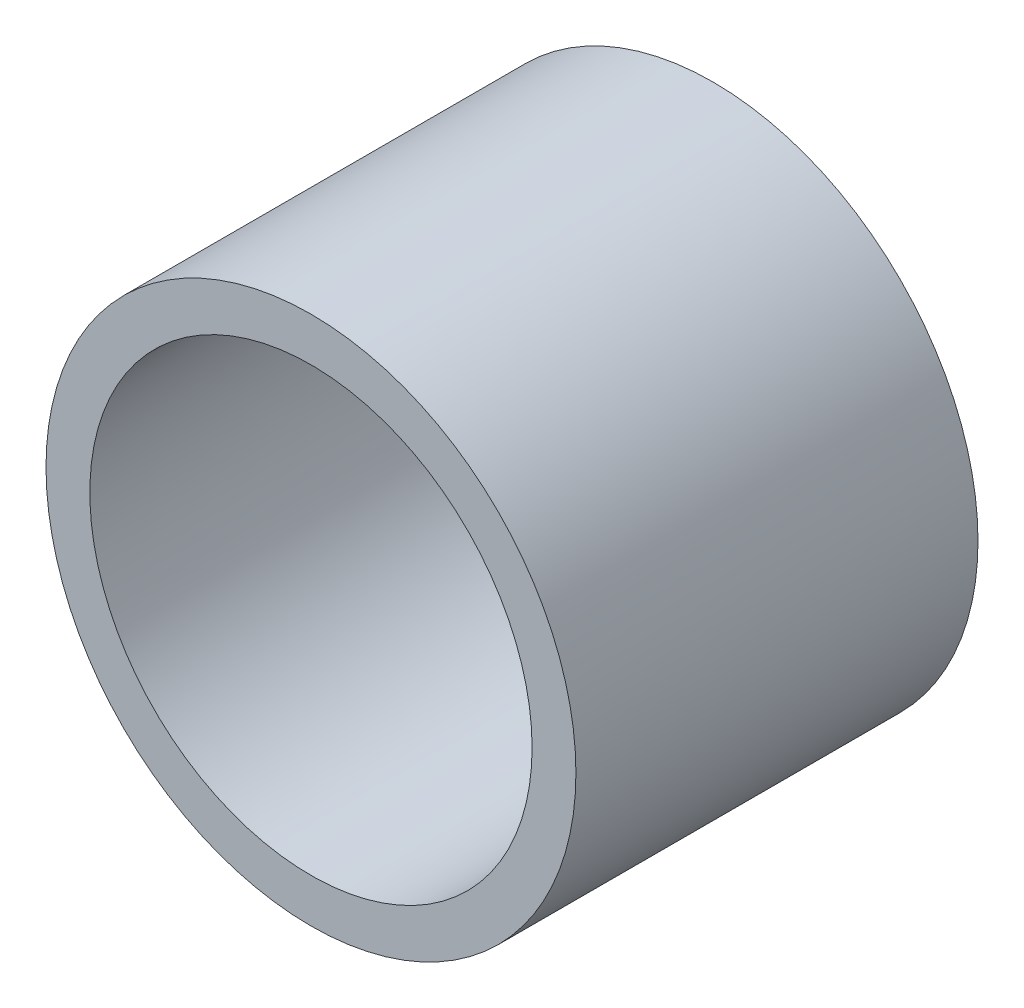
from build123d import *

# Parameters (mm, degrees)
SKETCH1_R           = 32.95
SKETCH1_R_2         = 27.5
BOSS_EXTRUDE1_DEPTH = 50


with BuildPart() as part:
    # Sketch1 → Boss-Extrude1 (new body)
    with BuildSketch(Plane.XY):
        Circle(SKETCH1_R)
        Circle(SKETCH1_R_2, mode=Mode.SUBTRACT)
    extrude(amount=BOSS_EXTRUDE1_DEPTH)


solid = part.part
